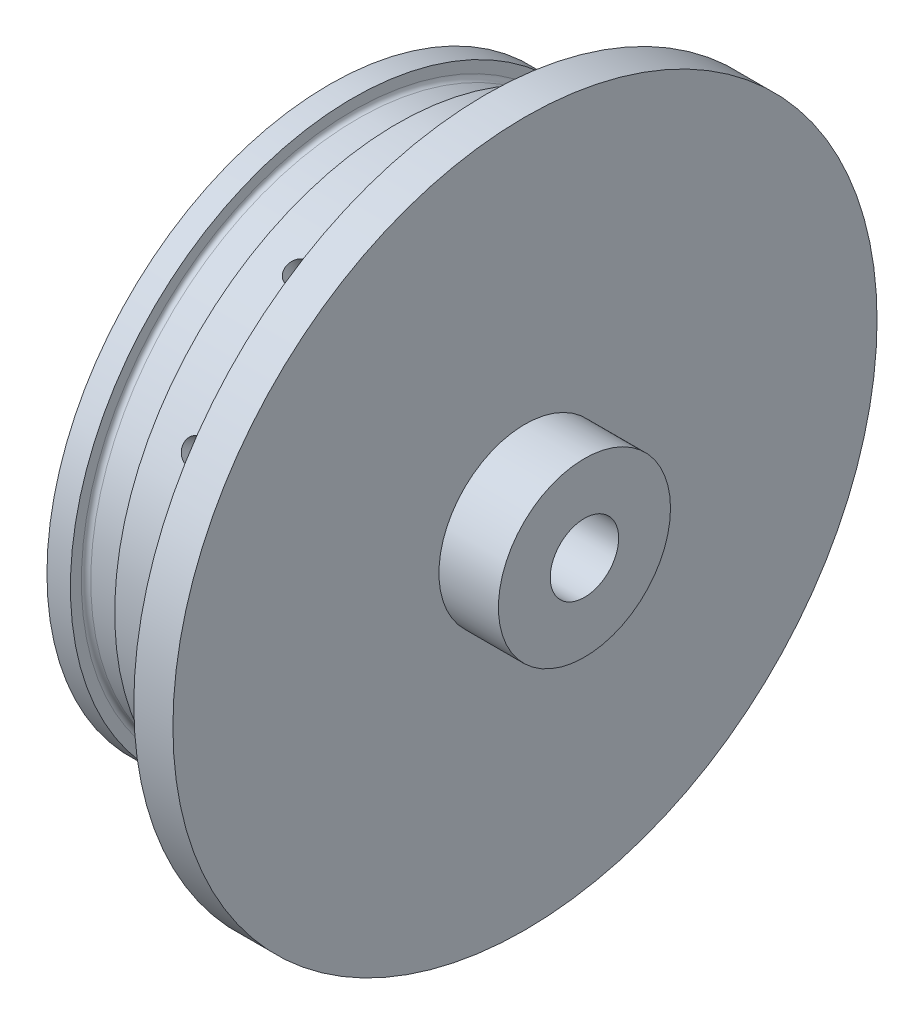
from build123d import *

# Parameters (mm, degrees)
SKETCH1_R               = 57.15
BOSS_EXTRUDE1_DEPTH     = 6.35
SKETCH2_R               = 45.847
BOSS_EXTRUDE2_DEPTH     = 25.4
SKETCH11_R              = 1.89865
CUT_EXTRUDE3_DEPTH      = 10.16
CIRPATTERN1_COUNT       = 12
SKETCH15_R              = 5.55625
CUT_EXTRUDE4_DEPTH      = 1
CUT_EXTRUDE4_DEPTH_BACK = 32.7500001
SKETCH17_R              = 13.97
SKETCH17_R_2            = 5.55625
BOSS_EXTRUDE3_DEPTH     = 9.652
SKETCH18_R              = 38.354
CUT_EXTRUDE5_DEPTH      = 6.604
SKETCH19_R              = 1.1303
CUT_EXTRUDE6_DEPTH      = 6.35


with BuildPart() as part:
    # Sketch1 → Boss-Extrude1 (new body)
    with BuildSketch(Plane(origin=(0, 0, 0), x_dir=(0, 0, -1), z_dir=(1, 0, 0))):
        Circle(SKETCH1_R)
    extrude(amount=BOSS_EXTRUDE1_DEPTH)

    # Sketch2 → Boss-Extrude2 (add)
    with BuildSketch(Plane.ZY):
        Circle(SKETCH2_R)
    extrude(amount=BOSS_EXTRUDE2_DEPTH)

    # Sketch11 → Cut-Extrude3 (cut)
    with BuildSketch(Plane(origin=(0, 0, -45.847), x_dir=(-1, 0, 0), z_dir=(0, 0, -1))):
        with Locations((7.62, 0)):
            Circle(SKETCH11_R)
    cut_extrude3 = extrude(amount=-CUT_EXTRUDE3_DEPTH, mode=Mode.SUBTRACT)

    # CirPattern1: Cut-Extrude3 ×12 about axis
    cirpattern1_axis = Axis((0, 0, 0), (1, 0, 0))
    for i in range(1, CIRPATTERN1_COUNT):
        add(cut_extrude3.rotate(cirpattern1_axis, i * 360 / CIRPATTERN1_COUNT), mode=Mode.SUBTRACT)

    # Sketch15 → Cut-Extrude4 (cut, two sides)
    with BuildSketch(Plane(origin=(6.35, 0, 0), x_dir=(0, 0, -1), z_dir=(1, 0, 0))) as cut_extrude4_sk:
        Circle(SKETCH15_R)
    extrude(amount=CUT_EXTRUDE4_DEPTH, mode=Mode.SUBTRACT)
    extrude(cut_extrude4_sk.sketch, amount=-CUT_EXTRUDE4_DEPTH_BACK, mode=Mode.SUBTRACT)

    # Sketch16 → Cut-Revolve1 (revolve, cut)
    with BuildSketch(Plane.XY):
        with BuildLine():
            Line((-21.59, 45.847), (-14.4018, 45.847))
            Line((-14.4018, 45.847), (-14.4018, 44.069))
            ThreePointArc((-14.4018, 44.069), (-14.624984633, 43.530184633), (-15.1638, 43.307))
            Line((-15.1638, 43.307), (-20.828, 43.307))
            ThreePointArc((-20.828, 43.307), (-21.366815367, 43.530184633), (-21.59, 44.069))
            Line((-21.59, 44.069), (-21.59, 45.847))
        make_face()
    revolve(axis=Axis((0, 0, 0), (-1, 0, 0)), mode=Mode.SUBTRACT)

    # Sketch17 → Boss-Extrude3 (add)
    with BuildSketch(Plane(origin=(6.35, 0, 0), x_dir=(0, 0, -1), z_dir=(1, 0, 0))):
        Circle(SKETCH17_R)
        Circle(SKETCH17_R_2, mode=Mode.SUBTRACT)
    extrude(amount=BOSS_EXTRUDE3_DEPTH)

    # Sketch18 → Cut-Extrude5 (cut)
    with BuildSketch(Plane.ZY.offset(25.4)):
        Circle(SKETCH18_R)
    extrude(amount=-CUT_EXTRUDE5_DEPTH, mode=Mode.SUBTRACT)

    # Sketch19 → Cut-Extrude6 (cut)
    with BuildSketch(Plane.ZY.offset(18.796)):
        with Locations((0, 33.3375)):
            Circle(SKETCH19_R)
        with Locations((23.573172318, 23.573172318)):
            Circle(SKETCH19_R)
        with Locations((33.3375, 0)):
            Circle(SKETCH19_R)
        with Locations((23.573172318, -23.573172318)):
            Circle(SKETCH19_R)
        with Locations((0, -33.3375)):
            Circle(SKETCH19_R)
        with Locations((-23.573172318, -23.573172318)):
            Circle(SKETCH19_R)
        with Locations((-33.3375, 0)):
            Circle(SKETCH19_R)
        with Locations((-23.573172318, 23.573172318)):
            Circle(SKETCH19_R)
    extrude(amount=-CUT_EXTRUDE6_DEPTH, mode=Mode.SUBTRACT)

    # Sketch20 → Cut-Revolve2 (revolve, cut)
    with BuildSketch(Plane.XY):
        Polygon((0, 0), (-18.796, 0), (-18.796, 27.94), (0, 15.875), align=None)
    revolve(axis=Axis((0, 0, 0), (-1, 0, 0)), mode=Mode.SUBTRACT)


solid = part.part
